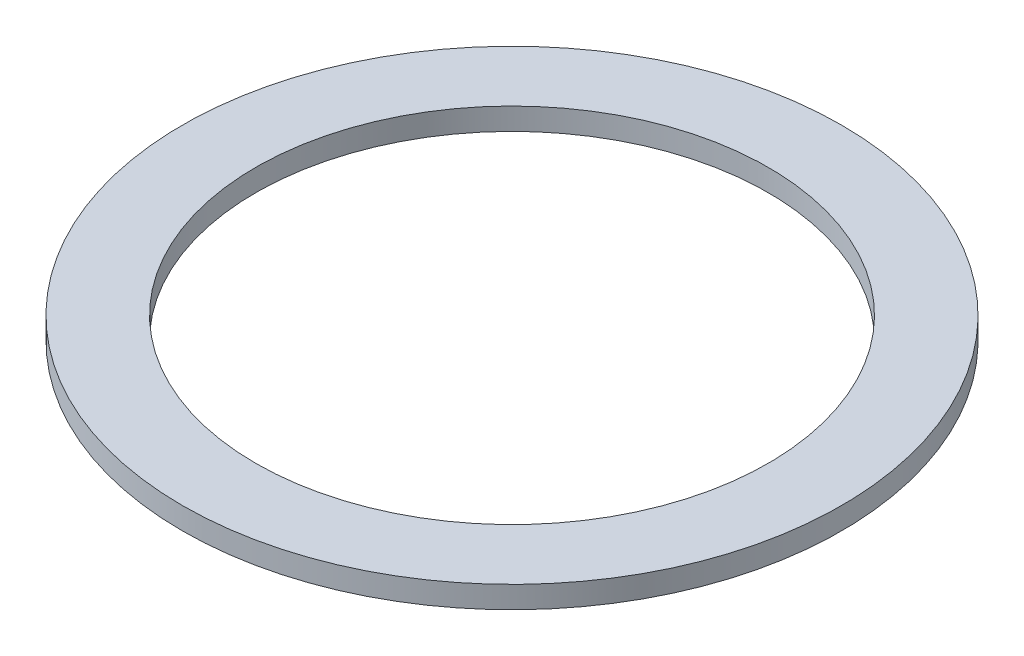
from build123d import *

# Parameters (mm, degrees)
CROQUIS1_R              = 45
CROQUIS1_R_2            = 35
SALIENTE_EXTRUIR1_DEPTH = 3


with BuildPart() as part:
    # Croquis1 → Saliente-Extruir1 (new body)
    with BuildSketch(Plane(origin=(0, 0, 0), x_dir=(1, 0, 0), z_dir=(0, 1, 0))):
        Circle(CROQUIS1_R)
        Circle(CROQUIS1_R_2, mode=Mode.SUBTRACT)
    extrude(amount=SALIENTE_EXTRUIR1_DEPTH)


solid = part.part
